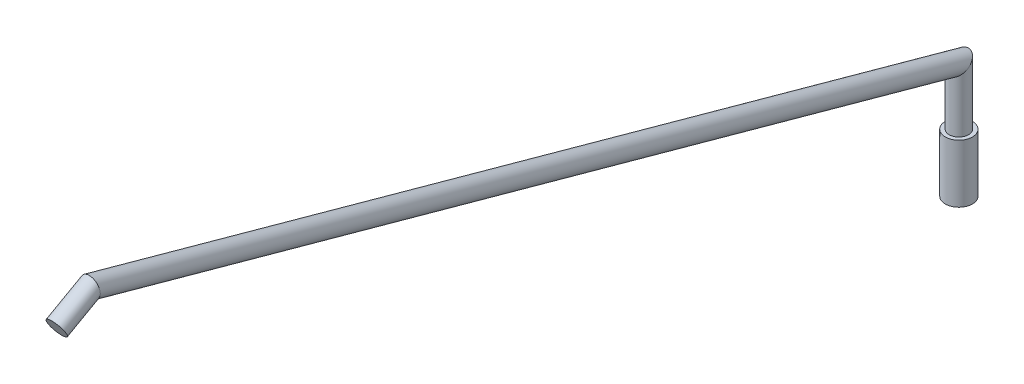
from build123d import *

# Parameters (mm, degrees)
SKETCH2_R           = 2.5
SKETCH3_R           = 3.5
BOSS_EXTRUDE1_DEPTH = 15


with BuildPart() as part:
    # Sweep1: sweep along a path in Sketch1
    with BuildLine(Plane(origin=(0, 0, 0), x_dir=(0, 0, -1), z_dir=(1, 0, 0))) as sweep1_path:
        Line((0, 0), (0, 30))
        Line((0, 30), (-224.277396019, 91.890417139))
        Line((-224.277396019, 91.890417139), (-233, 87))
    # Sketch2 → Sweep1 (sweep)
    with BuildSketch(Plane(origin=(0, 87, 233), x_dir=(1, 0, 0), z_dir=(0, -0.489041714, 0.872260398))):
        Circle(SKETCH2_R)
    sweep(path=sweep1_path.line, transition=Transition.RIGHT)

    # Sketch3 → Boss-Extrude1 (add)
    with BuildSketch(Plane.XZ):
        Circle(SKETCH3_R)
    extrude(amount=-BOSS_EXTRUDE1_DEPTH)


solid = part.part
